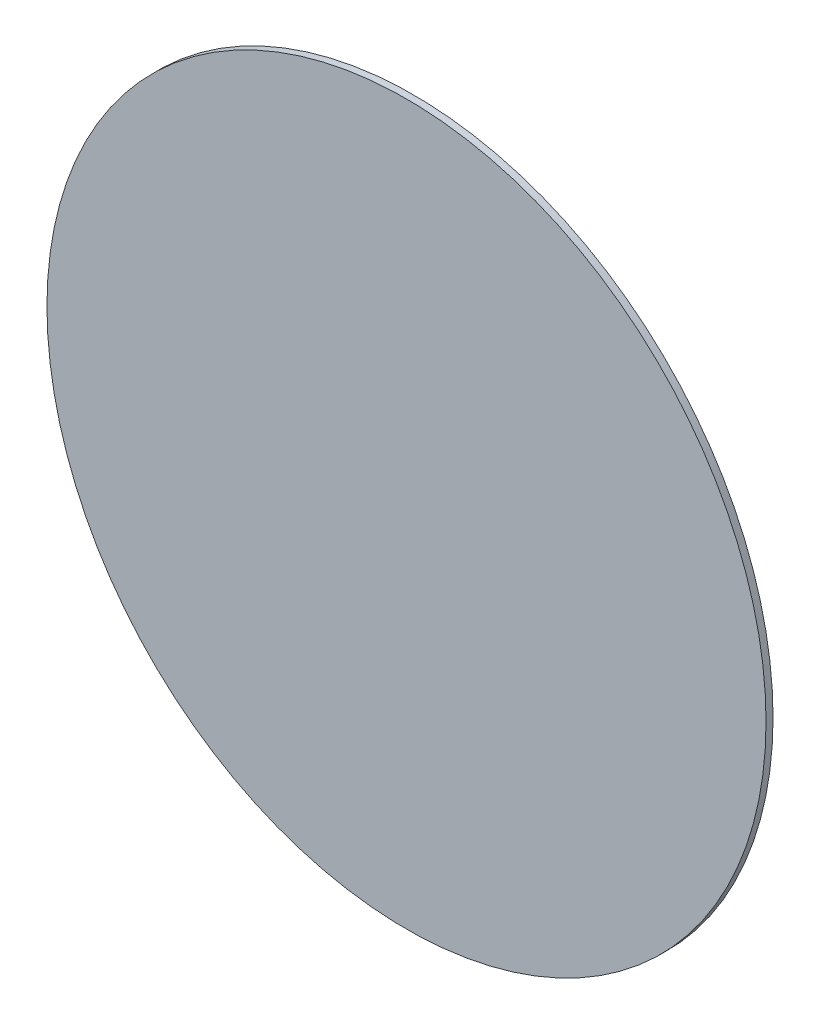
from build123d import *

# Parameters (mm, degrees)
SKETCH2_R           = 133.5
BOSS_EXTRUDE1_DEPTH = 2.6


with BuildPart() as part:
    # Sketch2 → Boss-Extrude1 (new body)
    with BuildSketch(Plane.XY):
        Circle(SKETCH2_R)
    extrude(amount=BOSS_EXTRUDE1_DEPTH)


solid = part.part
